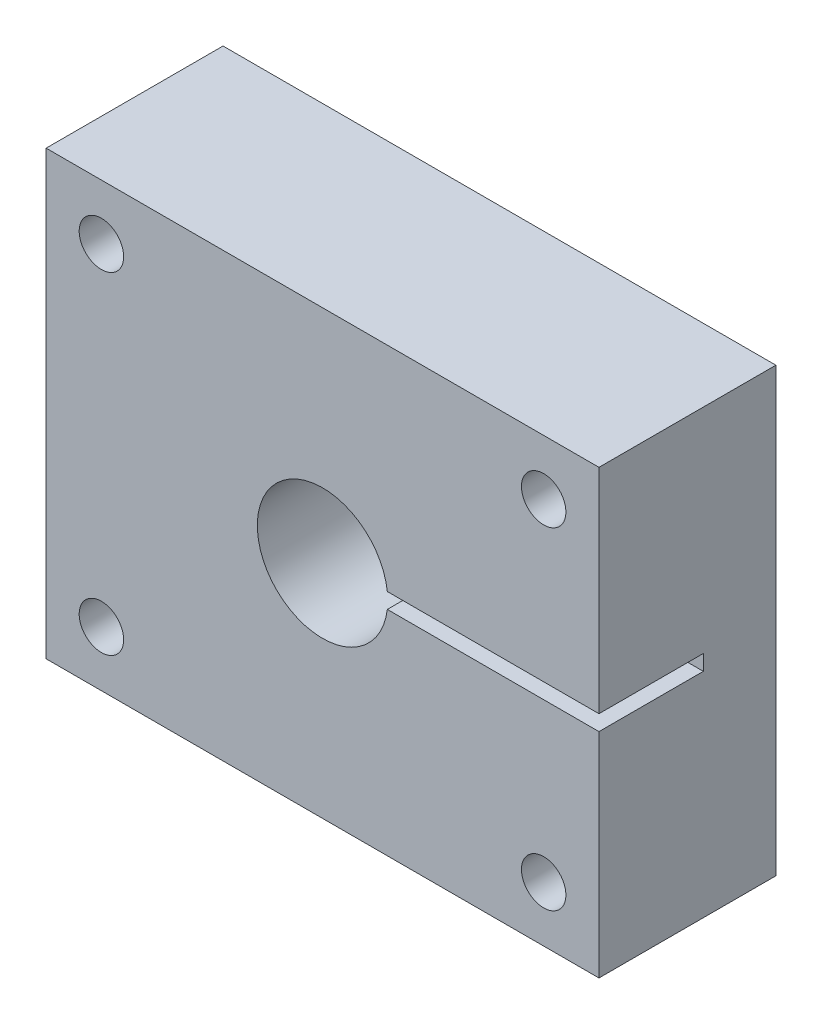
from build123d import *

# Parameters (mm, degrees)
SKETCH1_W               = 63.5
SKETCH1_H               = 50.8
BOSS_EXTRUDE1_DEPTH     = 20.32
SKETCH2_R               = 7.493
CUT_EXTRUDE1_DEPTH      = 11.9888
SKETCH3_W               = 31.75
SKETCH3_H               = 1.778
CUT_EXTRUDE2_DEPTH      = 11.9888
SKETCH9_R               = 1.9939
CUT_EXTRUDE3_DEPTH      = 11.9888
CUT_EXTRUDE4_START      = -6.331204
SKETCH10_R              = 7.493
CUT_EXTRUDE4_DEPTH      = 6.331204
SKETCH11_R              = 2.5527
CUT_EXTRUDE5_DEPTH      = 21.32
MIRROR2_COPY_1_SKETCH_R = 2.5527
MIRROR2_COPY_1_DEPTH    = 21.32


with BuildPart() as part:
    # Sketch1 → Boss-Extrude1 (new body)
    with BuildSketch(Plane.XY):
        Rectangle(SKETCH1_W, SKETCH1_H)
    extrude(amount=BOSS_EXTRUDE1_DEPTH)

    # Sketch2 → Cut-Extrude1 (cut)
    with BuildSketch(Plane.XY.offset(20.32)):
        Circle(SKETCH2_R)
    extrude(amount=-CUT_EXTRUDE1_DEPTH, mode=Mode.SUBTRACT)

    # Sketch3 → Cut-Extrude2 (cut)
    with BuildSketch(Plane.XY.offset(20.32)):
        with Locations((15.875, 0)):
            Rectangle(SKETCH3_W, SKETCH3_H)
    extrude(amount=-CUT_EXTRUDE2_DEPTH, mode=Mode.SUBTRACT)

    # Sketch9 → Cut-Extrude3 (cut)
    with BuildSketch(Plane.XY.offset(8.3312)):
        Circle(SKETCH9_R)
    extrude(amount=-CUT_EXTRUDE3_DEPTH, mode=Mode.SUBTRACT)

    # Sketch10 → Cut-Extrude4 (cut)
    with BuildSketch(Plane(origin=(0, 0, 0), x_dir=(-1, 0, 0), z_dir=(0, 0, -1)).offset(CUT_EXTRUDE4_START)):
        Circle(SKETCH10_R)
    extrude(amount=CUT_EXTRUDE4_DEPTH, mode=Mode.SUBTRACT)

    # Sketch11 → Cut-Extrude5 (cut, through all)
    with BuildSketch(Plane.XY.offset(20.32)):
        with Locations((-25.4, 19.05)):
            Circle(SKETCH11_R)
    cut_extrude5 = extrude(amount=-CUT_EXTRUDE5_DEPTH, mode=Mode.SUBTRACT)

    # Mirror1: Cut-Extrude5 across plane
    add(cut_extrude5.mirror(Plane(origin=(0, 0, 0), x_dir=(0, 0, 1), z_dir=(1, 0, 0))), mode=Mode.SUBTRACT)

    # Mirror2: Cut-Extrude5 across plane
    add(cut_extrude5.mirror(Plane.ZX), mode=Mode.SUBTRACT)

    # Mirror2 copy 1 sketch → Mirror2 copy 1 (cut, through all)
    with BuildSketch(Plane(origin=(0, 0, 20.32), x_dir=(-1, 0, 0), z_dir=(0, 0, 1))):
        with Locations((-25.4, 19.05)):
            Circle(MIRROR2_COPY_1_SKETCH_R)
    extrude(amount=-MIRROR2_COPY_1_DEPTH, mode=Mode.SUBTRACT)


solid = part.part
